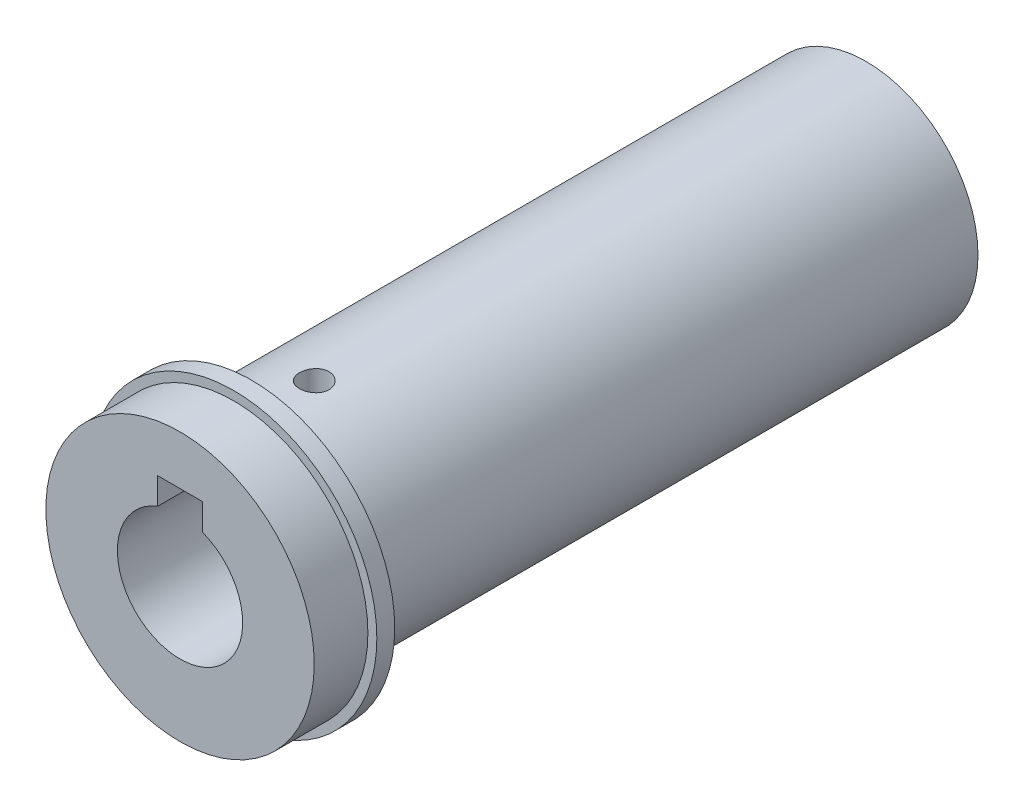
from build123d import *

# Parameters (mm, degrees)
SKETCH1_R                 = 12.5
BOSS_EXTRUDE1_DEPTH       = 68.7
SKETCH2_R                 = 16
BOSS_EXTRUDE2_DEPTH       = 2
SKETCH3_R                 = 15
BOSS_EXTRUDE3_DEPTH       = 6
CUT_EXTRUDE1_DEPTH        = 30
SKETCH6_W                 = 6
SKETCH6_H                 = 6
CUT_EXTRUDE2_DEPTH        = 35
M4X0_7_TAPPED_HOLE1_D     = 3.3
M4X0_7_TAPPED_HOLE1_DEPTH = 3


with BuildPart() as part:
    # Sketch1 → Boss-Extrude1 (new body)
    with BuildSketch(Plane.XY):
        Circle(SKETCH1_R)
    extrude(amount=BOSS_EXTRUDE1_DEPTH)

    # Sketch2 → Boss-Extrude2 (add)
    with BuildSketch(Plane.XY.offset(68.7)):
        Circle(SKETCH2_R)
    extrude(amount=BOSS_EXTRUDE2_DEPTH)

    # Sketch3 → Boss-Extrude3 (add)
    with BuildSketch(Plane.XY.offset(70.7)):
        Circle(SKETCH3_R)
    extrude(amount=BOSS_EXTRUDE3_DEPTH)

    # Sketch4 → Cut-Extrude1 (cut)
    with BuildSketch(Plane.XY.offset(76.7)):
        with BuildLine():
            Line((-2.5, 6.538348415), (-2.5, 4.5))
            Line((-2.5, 4.5), (2.5, 4.5))
            Line((2.5, 4.5), (2.5, 6.538348415))
            ThreePointArc((2.5, 6.538348415), (0, 7), (-2.5, 6.538348415))
        make_face()
        with BuildLine():
            Line((2.5, 4.5), (-2.5, 4.5))
            Line((-2.5, 4.5), (-2.5, 6.538348415))
            ThreePointArc((-2.5, 6.538348415), (-3.968626967, -5.766281297), (7, 0))
            ThreePointArc((7, 0), (5.766281297, 3.968626967), (2.5, 6.538348415))
            Line((2.5, 6.538348415), (2.5, 4.5))
        make_face()
        with BuildLine():
            Line((-2.5, 9.5), (-2.5, 6.538348415))
            ThreePointArc((-2.5, 6.538348415), (0, 7), (2.5, 6.538348415))
            Line((2.5, 6.538348415), (2.5, 9.5))
            Line((2.5, 9.5), (-2.5, 9.5))
        make_face()
    extrude(amount=-CUT_EXTRUDE1_DEPTH, mode=Mode.SUBTRACT)

    # Sketch6 → Cut-Extrude2 (cut)
    with BuildSketch(Plane(origin=(0, 0, 64.7), x_dir=(-1, 0, 0), z_dir=(0, 0, -1))):
        with Locations((0, -12.5)):
            Rectangle(SKETCH6_W, SKETCH6_H)
    extrude(amount=CUT_EXTRUDE2_DEPTH, mode=Mode.SUBTRACT)

    # M4x0.7 Tapped Hole1
    with Locations(Plane(origin=(0, 12.5, 0), x_dir=(1, 0, 0), z_dir=(0, 1, 0))):
        with Locations((0, -61.7)):
            Hole(M4X0_7_TAPPED_HOLE1_D / 2, depth=M4X0_7_TAPPED_HOLE1_DEPTH)


solid = part.part
